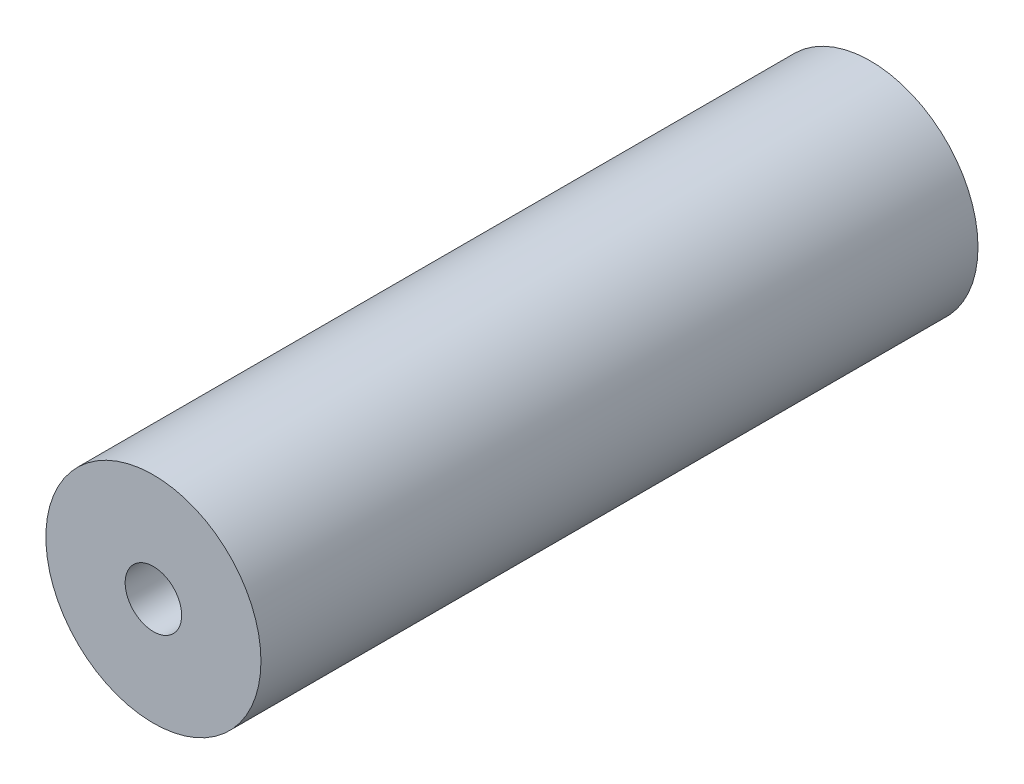
from build123d import *

# Parameters (mm, degrees)
SKETCH1_R                 = 9.525
BOSS_EXTRUDE1_DEPTH       = 31.75
M6X1_0_TAPPED_HOLE1_D     = 5
M6X1_0_TAPPED_HOLE1_DEPTH = 15.0114
M6X1_0_TAPPED_HOLE1_TIP   = 1.502151548
M6X1_0_TAPPED_HOLE2_D     = 5
M6X1_0_TAPPED_HOLE2_DEPTH = 15.0114
M6X1_0_TAPPED_HOLE2_TIP   = 1.502151548


with BuildPart() as part:
    # Sketch1 → Boss-Extrude1 (new body, symmetric)
    with BuildSketch(Plane.XY):
        Circle(SKETCH1_R)
    extrude(amount=BOSS_EXTRUDE1_DEPTH, both=True)

    # M6x1.0 Tapped Hole1
    with Locations(Plane.XY.offset(31.75)):
        with Locations((0, 0)):
            Hole(M6X1_0_TAPPED_HOLE1_D / 2, depth=M6X1_0_TAPPED_HOLE1_DEPTH)
            with Locations((0, 0, -(M6X1_0_TAPPED_HOLE1_DEPTH + M6X1_0_TAPPED_HOLE1_TIP / 2))):  # 118° drill point
                Cone(0, M6X1_0_TAPPED_HOLE1_D / 2, M6X1_0_TAPPED_HOLE1_TIP, mode=Mode.SUBTRACT)

    # M6x1.0 Tapped Hole2
    with Locations(Plane(origin=(0, 0, -31.75), x_dir=(-1, 0, 0), z_dir=(0, 0, -1))):
        with Locations((0, 0)):
            Hole(M6X1_0_TAPPED_HOLE2_D / 2, depth=M6X1_0_TAPPED_HOLE2_DEPTH)
            with Locations((0, 0, -(M6X1_0_TAPPED_HOLE2_DEPTH + M6X1_0_TAPPED_HOLE2_TIP / 2))):  # 118° drill point
                Cone(0, M6X1_0_TAPPED_HOLE2_D / 2, M6X1_0_TAPPED_HOLE2_TIP, mode=Mode.SUBTRACT)


solid = part.part
